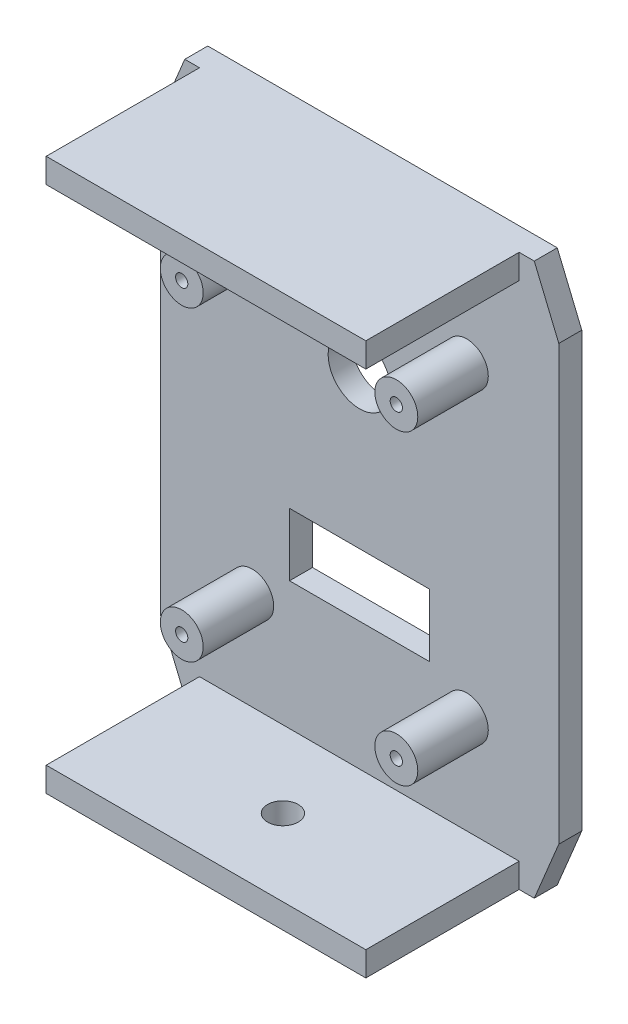
from build123d import *

# Parameters (mm, degrees)
BOSS_EXTRUDE1_DEPTH = 4.7625
SKETCH3_W           = 66.200858932
SKETCH3_H           = 5.079818348
BOSS_EXTRUDE2_DEPTH = 31.75
SKETCH4_W           = 28.999942
SKETCH4_H           = 12.9999994
CUT_EXTRUDE1_DEPTH  = 4.7625
SKETCH5_R           = 6.4999997
CUT_EXTRUDE2_DEPTH  = 4.7625
SKETCH6_R           = 3.175
CUT_EXTRUDE3_DEPTH  = 7.3025
SKETCH7_R           = 4.445
BOSS_EXTRUDE3_DEPTH = 14.605
SKETCH8_R           = 1.27
CUT_EXTRUDE4_DEPTH  = 50.8


with BuildPart() as part:
    # Sketch1 → Boss-Extrude1 (new body)
    with BuildSketch(Plane.XY):
        Polygon((30.222809818, 36.11360466), (25.142809818, 48.349181892), (-47.247190182, 48.349181892), (-52.327190182, 36.11360466), (-52.327190182, -53.715240876), (-47.247190182, -65.950818108), (25.142809818, -65.950818108), (30.222809818, -53.715240876), align=None)
    extrude(amount=BOSS_EXTRUDE1_DEPTH)

    # Sketch3 → Boss-Extrude2 (add)
    with BuildSketch(Plane.XY.offset(4.7625)):
        with Locations((-11.098760716, 45.809272718)):
            Rectangle(SKETCH3_W, SKETCH3_H)
        with Locations((-11.098760716, -63.410908934)):
            Rectangle(SKETCH3_W, SKETCH3_H)
    extrude(amount=BOSS_EXTRUDE2_DEPTH)

    # Sketch4 → Cut-Extrude1 (cut)
    with BuildSketch(Plane(origin=(0, 0, 0), x_dir=(-1, 0, 0), z_dir=(0, 0, -1))):
        with Locations((11.052190182, -27.850818108)):
            Rectangle(SKETCH4_W, SKETCH4_H)
    extrude(amount=-CUT_EXTRUDE1_DEPTH, mode=Mode.SUBTRACT)

    # Sketch5 → Cut-Extrude2 (cut)
    with BuildSketch(Plane(origin=(0, 0, 0), x_dir=(-1, 0, 0), z_dir=(0, 0, -1))):
        with Locations((11.052190182, 10.249181892)):
            Circle(SKETCH5_R)
    extrude(amount=-CUT_EXTRUDE2_DEPTH, mode=Mode.SUBTRACT)

    # Sketch6 → Cut-Extrude3 (cut)
    with BuildSketch(Plane.XZ.offset(65.950818108)):
        with Locations((-11.052190182, 20.6375)):
            Circle(SKETCH6_R)
    extrude(amount=-CUT_EXTRUDE3_DEPTH, mode=Mode.SUBTRACT)

    # Sketch7 → Boss-Extrude3 (add)
    with BuildSketch(Plane.XY.offset(4.7625)):
        with Locations((11.172809818, -40.550818108)):
            Circle(SKETCH7_R)
        with Locations((-33.277190182, -40.550818108)):
            Circle(SKETCH7_R)
        with Locations((11.172809818, 22.949181892)):
            Circle(SKETCH7_R)
        with Locations((-33.277190182, 22.949181892)):
            Circle(SKETCH7_R)
    extrude(amount=BOSS_EXTRUDE3_DEPTH)

    # Sketch8 → Cut-Extrude4 (cut)
    with BuildSketch(Plane.XY.offset(19.3675)):
        with Locations((-33.277190182, 22.949181892)):
            Circle(SKETCH8_R)
        with Locations((11.172809818, 22.949181892)):
            Circle(SKETCH8_R)
        with Locations((11.172809818, -40.550818108)):
            Circle(SKETCH8_R)
        with Locations((-33.277190182, -40.550818108)):
            Circle(SKETCH8_R)
    extrude(amount=-CUT_EXTRUDE4_DEPTH, mode=Mode.SUBTRACT)


solid = part.part
